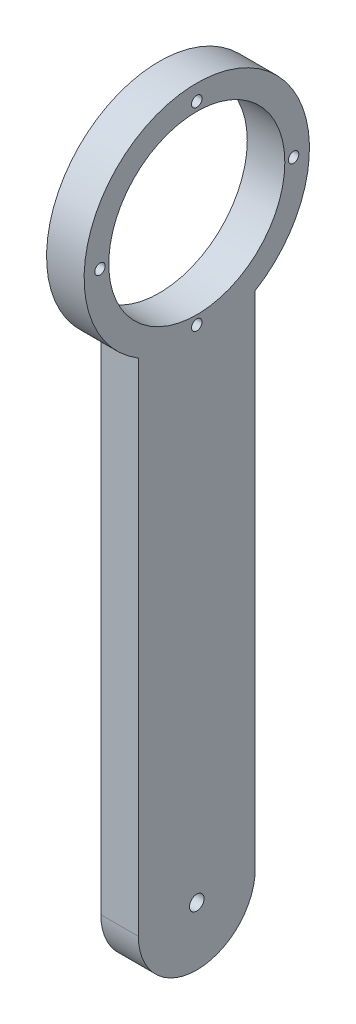
from build123d import *

# Parameters (mm, degrees)
EXTRUDE_6_DEPTH      = 9
SKETCH_8_R           = 23.25
CUT_EXTRUDE_6_DEPTH  = 7
SKETCH_9_R           = 19.25
CUT_EXTRUDE_7_DEPTH  = 7
SKETCH_13_R          = 23.25
EXTRUDE_9_DEPTH      = 9
SKETCH_14_R          = 21.1
CUT_EXTRUDE_8_DEPTH  = 10
SKETCH_26_R          = 1.75
CUT_EXTRUDE_14_DEPTH = 10
SKETCH_25_R          = 1.25
CUT_EXTRUDE_15_DEPTH = 10


with BuildPart() as part:
    # 草图1 → 凸台-拉伸6 (new body)
    with BuildSketch(Plane(origin=(0, 0, 0), x_dir=(0, 0, -1), z_dir=(1, 0, 0))):
        with BuildLine():
            Line((0, 0), (0, 120))
            ThreePointArc((0, 120), (14, 170.086792761), (28, 120))
            Line((28, 120), (28, 0))
            ThreePointArc((28, 0), (14, -14), (0, 0))
        make_face()
    extrude(amount=EXTRUDE_6_DEPTH)

    # 草图8 → 切除-拉伸6 (cut)
    with BuildSketch(Plane(origin=(9, 0, 0), x_dir=(0, 0, -1), z_dir=(1, 0, 0))):
        with Locations((14, 143.086792761)):
            Circle(SKETCH_8_R)
    extrude(amount=-CUT_EXTRUDE_6_DEPTH, mode=Mode.SUBTRACT)

    # 草图9 → 切除-拉伸7 (cut)
    with BuildSketch(Plane(origin=(2, 0, 0), x_dir=(0, 0, -1), z_dir=(1, 0, 0))):
        with Locations((14, 143.086792761)):
            Circle(SKETCH_9_R)
    extrude(amount=-CUT_EXTRUDE_7_DEPTH, mode=Mode.SUBTRACT)

    # 草图13 → 凸台-拉伸9 (add)
    with BuildSketch(Plane(origin=(9, 0, 0), x_dir=(0, 0, -1), z_dir=(1, 0, 0))):
        with Locations((14, 143.086792761)):
            Circle(SKETCH_13_R)
    extrude(amount=-EXTRUDE_9_DEPTH)

    # 草图14 → 切除-拉伸8 (cut)
    with BuildSketch(Plane(origin=(9, 0, 0), x_dir=(0, 0, -1), z_dir=(1, 0, 0))):
        with Locations((14, 143.086792761)):
            Circle(SKETCH_14_R)
    extrude(amount=-CUT_EXTRUDE_8_DEPTH, mode=Mode.SUBTRACT)

    # 草图26 → 切除-拉伸14 (cut)
    with BuildSketch(Plane(origin=(9, 0, 0), x_dir=(0, 0, -1), z_dir=(1, 0, 0))):
        with Locations((14, 0)):
            Circle(SKETCH_26_R)
    extrude(amount=-CUT_EXTRUDE_14_DEPTH, mode=Mode.SUBTRACT)

    # 草图25 → 切除-拉伸15 (cut)
    with BuildSketch(Plane.ZY):
        with Locations((9.2, 143.086792761)):
            Circle(SKETCH_25_R)
        with Locations((-14, 119.886792761)):
            Circle(SKETCH_25_R)
        with Locations((-37.2, 143.086792761)):
            Circle(SKETCH_25_R)
        with Locations((-14, 166.286792761)):
            Circle(SKETCH_25_R)
    extrude(amount=-CUT_EXTRUDE_15_DEPTH, mode=Mode.SUBTRACT)


solid = part.part
